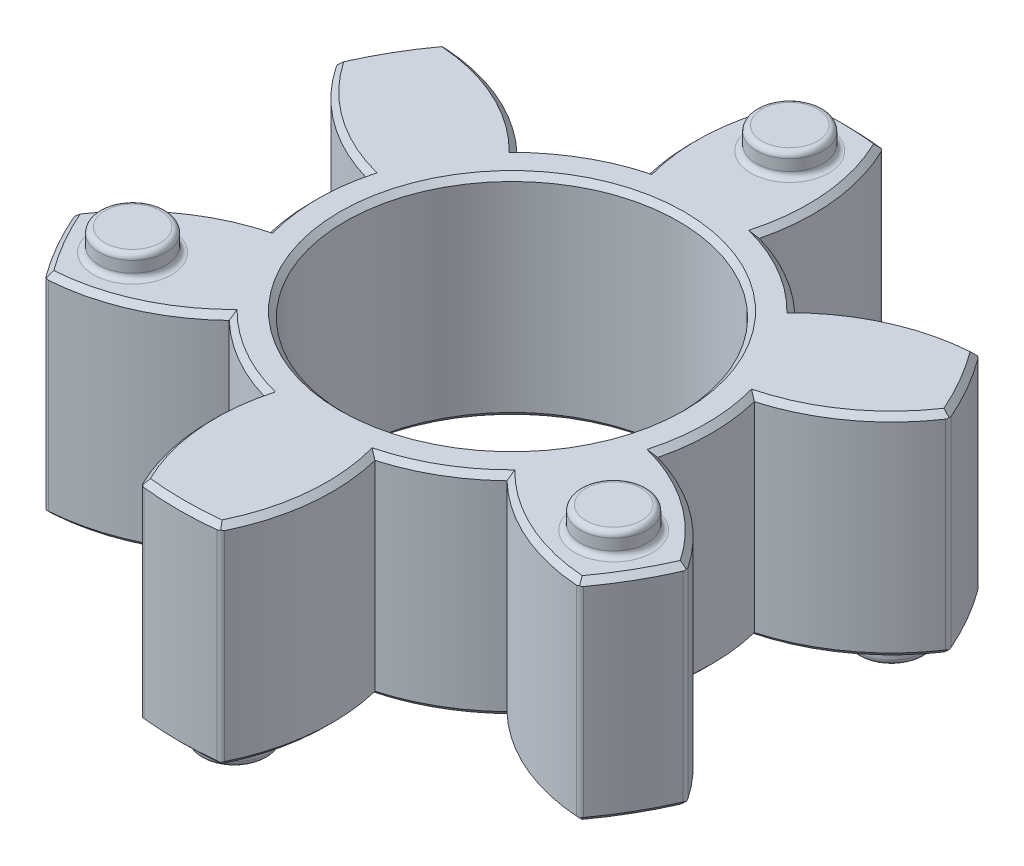
from build123d import *

# Parameters (mm, degrees)
BODY_SKETCH_R            = 15
BODY_DEPTH               = 4.75
BODY_HOLE_SKETCH_R       = 7.5
BODY_HOLE_DEPTH          = 5.75
BODY_HOLE_DEPTH_BACK     = 5.75
LEG_SKECH_OUTSIDE_W      = 40.696
LEG_SKECH_OUTSIDE_H      = 40.696
LEGS_DEPTH               = 5.75
LEGS_DEPTH_BACK          = 5.75
AESTHETIC_CHAMFER_SIZE   = 0.25
TOP_START                = 4.75
TOP_DISTANCE_SKETCH_R    = 1.5
TOP_DISTANCE_DEPTH       = 1
BOTTOM_START             = -4.75
BOTTOM_DISTANCE_SKETCH_R = 1.5
BOTTOM_DISTANCE_DEPTH    = 1
AESTHETIC_FILLET_R       = 0.25


with BuildPart() as part:
    # Body Sketch → Body (new body, symmetric)
    with BuildSketch(Plane(origin=(0, 0, 0), x_dir=(1, 0, 0), z_dir=(0, 1, 0))):
        Circle(BODY_SKETCH_R)
    extrude(amount=BODY_DEPTH, both=True)

    # Body Hole Sketch → Body Hole (cut, two sides)
    with BuildSketch(Plane(origin=(0, 0, 0), x_dir=(1, 0, 0), z_dir=(0, 1, 0))) as body_hole_sk:
        Circle(BODY_HOLE_SKETCH_R)
    extrude(amount=BODY_HOLE_DEPTH, mode=Mode.SUBTRACT)
    extrude(body_hole_sk.sketch, amount=-BODY_HOLE_DEPTH_BACK, mode=Mode.SUBTRACT)

    # Leg Skech outside → Legs (cut, two sides)
    with BuildSketch(Plane(origin=(0, 0, 0), x_dir=(1, 0, 0), z_dir=(0, 1, 0))) as legs_sk:
        Rectangle(LEG_SKECH_OUTSIDE_W, LEG_SKECH_OUTSIDE_H)
        with BuildLine():
            ThreePointArc((-2.483308569, 8.650617235), (-4.5, 7.794228634), (-6.25, 6.475916923))
            ThreePointArc((-6.25, 6.475916923), (-10.325299688, 8.733308569), (-14.983308569, 8.650617235))
            ThreePointArc((-14.983308569, 8.650617235), (-12.725916923, 4.575317547), (-8.733308569, 2.174700312))
            ThreePointArc((-8.733308569, 2.174700312), (-9, 0), (-8.733308569, -2.174700312))
            ThreePointArc((-8.733308569, -2.174700312), (-12.725916923, -4.575317547), (-14.983308569, -8.650617235))
            ThreePointArc((-14.983308569, -8.650617235), (-10.325299688, -8.733308569), (-6.25, -6.475916923))
            ThreePointArc((-6.25, -6.475916923), (-4.5, -7.794228634), (-2.483308569, -8.650617235))
            ThreePointArc((-2.483308569, -8.650617235), (-2.400617235, -13.308626116), (0, -17.301234471))
            ThreePointArc((0, -17.301234471), (2.400617235, -13.308626116), (2.483308569, -8.650617235))
            ThreePointArc((2.483308569, -8.650617235), (4.5, -7.794228634), (6.25, -6.475916923))
            ThreePointArc((6.25, -6.475916923), (10.325299688, -8.733308569), (14.983308569, -8.650617235))
            ThreePointArc((14.983308569, -8.650617235), (12.725916923, -4.575317547), (8.733308569, -2.174700312))
            ThreePointArc((8.733308569, -2.174700312), (9, 0), (8.733308569, 2.174700312))
            ThreePointArc((8.733308569, 2.174700312), (12.725916923, 4.575317547), (14.983308569, 8.650617235))
            ThreePointArc((14.983308569, 8.650617235), (10.325299688, 8.733308569), (6.25, 6.475916923))
            ThreePointArc((6.25, 6.475916923), (4.5, 7.794228634), (2.483308569, 8.650617235))
            ThreePointArc((2.483308569, 8.650617235), (2.400617235, 13.308626116), (0, 17.301234471))
            ThreePointArc((0, 17.301234471), (-2.400617235, 13.308626116), (-2.483308569, 8.650617235))
        make_face(mode=Mode.SUBTRACT)
    extrude(amount=LEGS_DEPTH, mode=Mode.SUBTRACT)
    extrude(legs_sk.sketch, amount=-LEGS_DEPTH_BACK, mode=Mode.SUBTRACT)

    # Aesthetic Chamfer
    aesthetic_chamfer_edges = [part.edges().sort_by_distance(p)[0] for p in [
        (12.990381057, -4.75, 7.5),
        (12.990381057, -4.75, -7.5),
        (0, -4.75, -15),
        (-12.990381057, -4.75, -7.5),
        (-12.990381057, -4.75, 7.5),
        (0, -4.75, 15),
        (-8.903773274, -4.75, 8.250282015),
        (-11.596840451, -4.75, -3.585752837),
        (-2.693067177, -4.75, -11.836034852),
        (8.903773274, -4.75, -8.250282015),
        (11.596840451, -4.75, 3.585752837),
        (2.693067177, -4.75, 11.836034852),
        (12.990381057, 4.75, 7.5),
        (12.990381057, 4.75, -7.5),
        (0, 4.75, -15),
        (-12.990381057, 4.75, -7.5),
        (-12.990381057, 4.75, 7.5),
        (0, 4.75, 15),
        (4.5, -4.75, 7.794228634),
        (8.903773274, -4.75, 8.250282015),
        (9, -4.75, 0),
        (11.596840451, -4.75, -3.585752837),
        (4.5, -4.75, -7.794228634),
        (2.693067177, -4.75, -11.836034852),
        (-4.5, -4.75, -7.794228634),
        (-8.903773274, -4.75, -8.250282015),
        (-9, -4.75, 0),
        (-11.596840451, -4.75, 3.585752837),
        (-4.5, -4.75, 7.794228634),
        (-2.693067177, -4.75, 11.836034852),
        (-2.693067177, 4.75, 11.836034852),
        (2.693067177, 4.75, 11.836034852),
        (8.903773274, 4.75, 8.250282015),
        (11.596840451, 4.75, 3.585752837),
        (11.596840451, 4.75, -3.585752837),
        (8.903773274, 4.75, -8.250282015),
        (2.693067177, 4.75, -11.836034852),
        (-2.693067177, 4.75, -11.836034852),
        (-8.903773274, 4.75, -8.250282015),
        (-11.596840451, 4.75, -3.585752837),
        (-11.596840451, 4.75, 3.585752837),
        (-8.903773274, 4.75, 8.250282015),
        (4.5, 4.75, 7.794228634),
        (9, 4.75, 0),
        (4.5, 4.75, -7.794228634),
        (-4.5, 4.75, -7.794228634),
        (-9, 4.75, 0),
        (-4.5, 4.75, 7.794228634),
        (-7.5, -4.75, 0),
        (-7.5, 4.75, 0),
    ]]
    chamfer(aesthetic_chamfer_edges, length=AESTHETIC_CHAMFER_SIZE)

    # Top Distance Sketch → Top Distance (add)
    with BuildSketch(Plane(origin=(0, 0, 0), x_dir=(1, 0, 0), z_dir=(0, 1, 0)).offset(TOP_START)):
        with Locations((0, 12.5)):
            Circle(TOP_DISTANCE_SKETCH_R)
        with Locations((10.825317547, -6.25)):
            Circle(TOP_DISTANCE_SKETCH_R)
        with Locations((-10.825317547, -6.25)):
            Circle(TOP_DISTANCE_SKETCH_R)
    extrude(amount=TOP_DISTANCE_DEPTH)

    # Bottom Distance Sketch → Bottom Distance (add)
    with BuildSketch(Plane(origin=(0, 0, 0), x_dir=(1, 0, 0), z_dir=(0, 1, 0)).offset(BOTTOM_START)):
        with Locations((0, -12.5)):
            Circle(BOTTOM_DISTANCE_SKETCH_R)
        with Locations((-10.825317547, 6.25)):
            Circle(BOTTOM_DISTANCE_SKETCH_R)
        with Locations((10.825317547, 6.25)):
            Circle(BOTTOM_DISTANCE_SKETCH_R)
    extrude(amount=-BOTTOM_DISTANCE_DEPTH)

    # Aesthetic Fillet
    aesthetic_fillet_edges = [part.edges().sort_by_distance(p)[0] for p in [
        (12.01, 0, 8.986651212),
        (13.787668244, 0, 5.907639494),
        (13.787668244, 0, -5.907639494),
        (12.01, 0, -8.986651212),
        (1.777668244, 0, -14.894290705),
        (-1.777668244, 0, -14.894290705),
        (-12.01, 0, -8.986651212),
        (-13.787668244, 0, -5.907639494),
        (-13.787668244, 0, 5.907639494),
        (-12.01, 0, 8.986651212),
        (-1.777668244, 0, 14.894290705),
        (1.777668244, 0, 14.894290705),
        (-1.5, 4.75, -12.5),
        (-1.5, 5.75, -12.5),
        (9.325317547, 4.75, 6.25),
        (9.325317547, 5.75, 6.25),
        (-12.325317547, 4.75, 6.25),
        (-12.325317547, 5.75, 6.25),
        (-12.325317547, -4.75, -6.25),
        (-12.325317547, -5.75, -6.25),
        (9.325317547, -4.75, -6.25),
        (9.325317547, -5.75, -6.25),
        (-1.5, -4.75, 12.5),
        (-1.5, -5.75, 12.5),
    ]]
    fillet(aesthetic_fillet_edges, radius=AESTHETIC_FILLET_R)


solid = part.part
